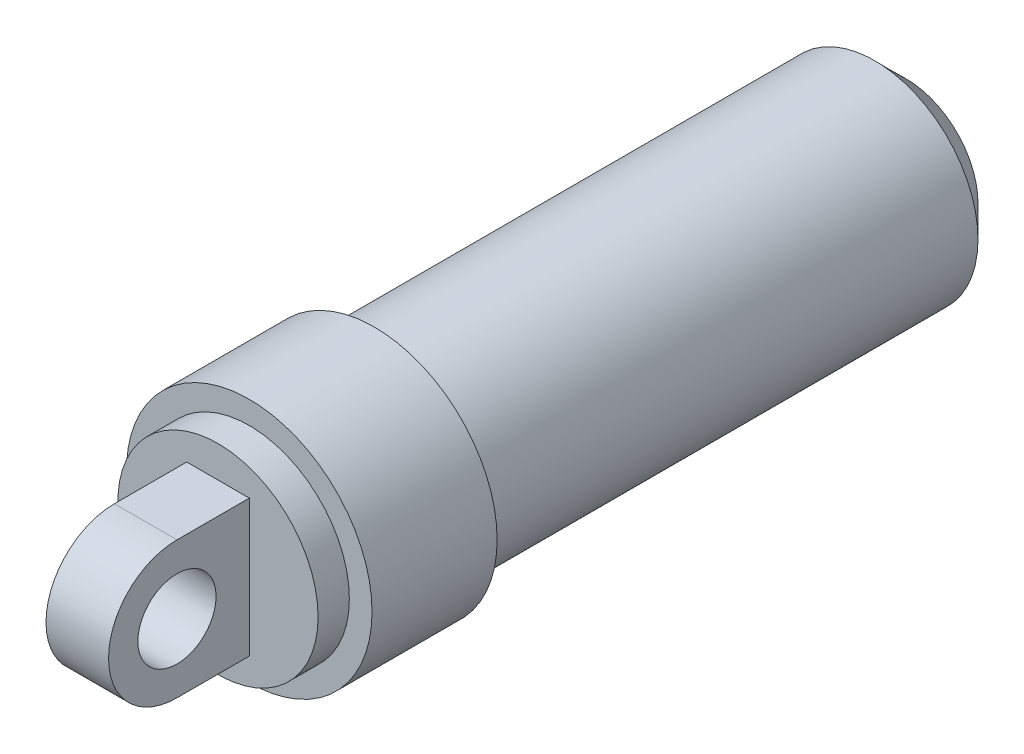
from build123d import *

# Parameters (mm, degrees)
SKETCH2_R            = 6.6
EXTERNAL_SHOCK_DEPTH = 34
SHOCK_CHAMFER_SIZE   = 2
SKETCH3_R            = 7.85
CYLINDER_A_DEPTH     = 8
SKETCH4_R            = 6.4
CYLINDER_B_DEPTH     = 2
MOUNTING_BOSS_DEPTH  = 2
SKETCH6_R            = 2.5
MOUNTING_HOLE_DEPTH  = 4
SKETCH7_R            = 1.5
INNER_HOLE_DEPTH     = 35


with BuildPart() as part:
    # Sketch2 → External Shock (new body)
    with BuildSketch(Plane.XY):
        Circle(SKETCH2_R)
    extrude(amount=EXTERNAL_SHOCK_DEPTH)

    # Shock Chamfer
    shock_chamfer_edges = [part.edges().sort_by_distance(p)[0] for p in [
        (-6.6, 0, 0),
    ]]
    chamfer(shock_chamfer_edges, length=SHOCK_CHAMFER_SIZE)

    # Sketch3 → Cylinder A (add)
    with BuildSketch(Plane.XY.offset(34)):
        Circle(SKETCH3_R)
    extrude(amount=CYLINDER_A_DEPTH)

    # Sketch4 → Cylinder B (add)
    with BuildSketch(Plane.XY.offset(42)):
        Circle(SKETCH4_R)
    extrude(amount=CYLINDER_B_DEPTH)

    # Sketch5 → Mounting Boss (add, symmetric)
    with BuildSketch(Plane(origin=(0, 0, 0), x_dir=(0, 0, -1), z_dir=(1, 0, 0))):
        with BuildLine():
            Line((-48.625, -4.375), (-44, -4.375))
            Line((-44, -4.375), (-44, 4.375))
            Line((-44, 4.375), (-48.625, 4.375))
            ThreePointArc((-48.625, 4.375), (-53, 0), (-48.625, -4.375))
        make_face()
    extrude(amount=MOUNTING_BOSS_DEPTH, both=True)

    # Sketch6 → Mounting Hole (cut)
    with BuildSketch(Plane.ZY.offset(2)):
        with Locations((48.625, 0)):
            Circle(SKETCH6_R)
    extrude(amount=-MOUNTING_HOLE_DEPTH, mode=Mode.SUBTRACT)

    # Sketch7 → Inner Hole (cut)
    with BuildSketch(Plane(origin=(0, 0, 0), x_dir=(-1, 0, 0), z_dir=(0, 0, -1))):
        Circle(SKETCH7_R)
    extrude(amount=-INNER_HOLE_DEPTH, mode=Mode.SUBTRACT)


solid = part.part
